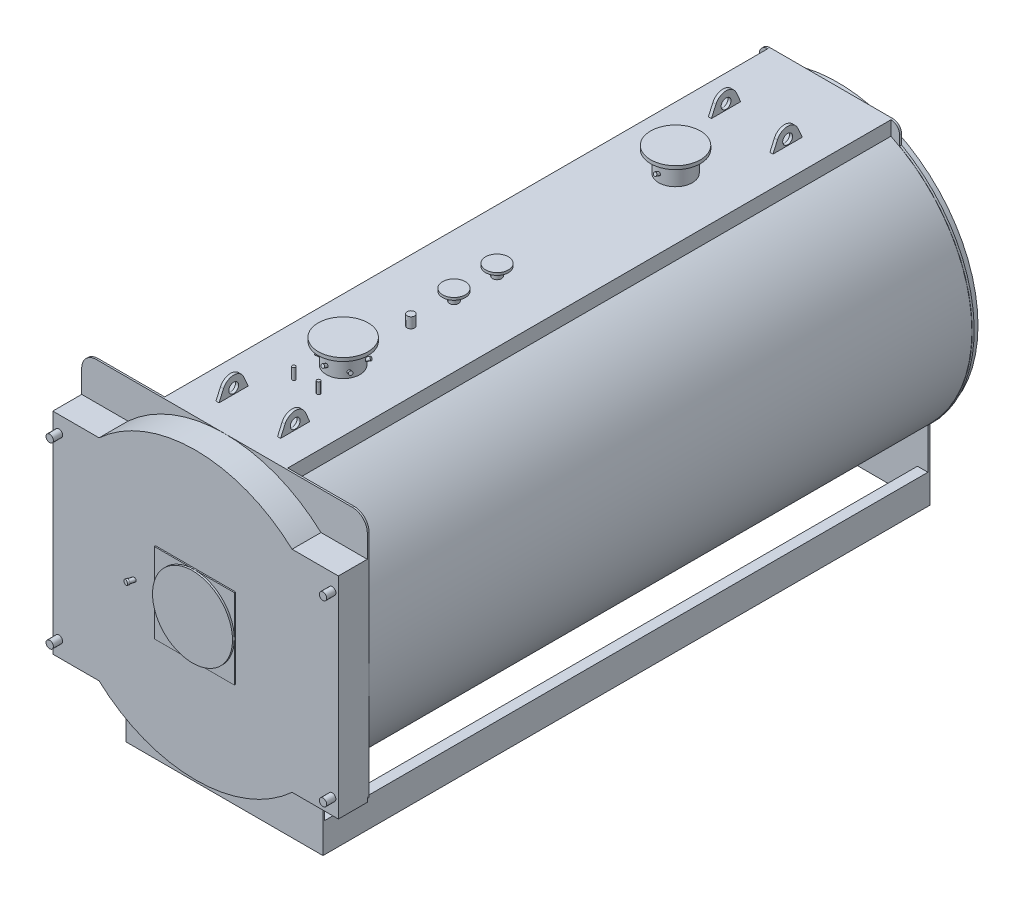
from build123d import *

# Parameters (mm, degrees)
PIASTRA_ANTERIORE_DEPTH       = 14
CORPO_DEPTH                   = 4900
PIASTRA_POSTERIORE_DEPTH      = 16
BASAMENTO_DEPTH               = 4900
ESTRUSIONE_ESTRUSIONE3_DEPTH  = 235
SCHIZZO8_W                    = 650
SCHIZZO8_H                    = 650
ESTRUSIONE_ESTRUSIONE4_DEPTH  = 10
SCHIZZO9_R                    = 325
ESTRUSIONE_ESTRUSIONE5_DEPTH  = 15
SCHIZZO12_R                   = 30
ESTRUSIONE_ESTRUSIONE6_DEPTH  = 75
SCHIZZO13_R                   = 136.5
ESTRUSIONE_ESTRUSIONE7_DEPTH  = 1355
SCHIZZO14_R                   = 202.5
ESTRUSIONE_ESTRUSIONE8_DEPTH  = 28
SCHIZZO13_3_R                 = 36.5
ESTRUSIONE_ESTRUSIONE9_DEPTH  = 1250
SCHIZZO15_R                   = 92.5
ESTRUSIONE_ESTRUSIONE10_DEPTH = 20
SCHIZZO13_4_R                 = 30.15
ESTRUSIONE_ESTRUSIONE11_DEPTH = 1245
SCHIZZO13_5_R                 = 13.35
ESTRUSIONE_ESTRUSIONE12_DEPTH = 1250
RIPETIZIONECIRCOLARE1_COUNT   = 3
SCHIZZO21_R                   = 24.15
ESTRUSIONE_ESTRUSIONE13_DEPTH = 149
SCHIZZO21_3_R                 = 24.15
ESTRUSIONE_ESTRUSIONE14_DEPTH = 50
SCHIZZO22_R                   = 75
ESTRUSIONE_ESTRUSIONE15_DEPTH = 16
GOLFARE_START                 = 250
SCHIZZO23_R                   = 40
GOLFARE_DEPTH                 = 12.5


with BuildPart() as part:
    # Schizzo1 → piastra anteriore (new body)
    with BuildSketch(Plane.XY):
        with BuildLine():
            Line((-1040, 2570), (1040, 2570))
            ThreePointArc((1040, 2570), (1124.852813742, 2534.852813742), (1160, 2450))
            Line((1160, 2450), (1160, 595))
            ThreePointArc((1160, 595), (1148.284271247, 566.715728753), (1120, 555))
            Line((1120, 555), (800, 555))
            Line((800, 555), (800, 0))
            Line((800, 0), (-800, 0))
            Line((-800, 0), (-800, 555))
            Line((-800, 555), (-1120, 555))
            ThreePointArc((-1120, 555), (-1148.284271247, 566.715728753), (-1160, 595))
            Line((-1160, 595), (-1160, 2450))
            ThreePointArc((-1160, 2450), (-1124.852813742, 2534.852813742), (-1040, 2570))
        make_face()
    extrude(amount=-PIASTRA_ANTERIORE_DEPTH)

    # Schizzo2 → corpo (add)
    with BuildSketch(Plane(origin=(0, 0, -14), x_dir=(-1, 0, 0), z_dir=(0, 0, -1))):
        with BuildLine():
            Line((500, 2453.937857346), (500, 2570))
            Line((500, 2570), (-500, 2570))
            Line((-500, 2570), (-500, 2453.937857346))
            ThreePointArc((-500, 2453.937857346), (0, 252.5), (500, 2453.937857346))
        make_face()
        with BuildLine():
            Line((490, 2447.620474933), (490, 2560))
            Line((490, 2560), (-490, 2560))
            Line((-490, 2560), (-490, 2447.620474933))
            ThreePointArc((-490, 2447.620474933), (0, 262.5), (490, 2447.620474933))
        make_face(mode=Mode.SUBTRACT)
    extrude(amount=CORPO_DEPTH)

    # Schizzo3 → piastra posteriore (add)
    with BuildSketch(Plane(origin=(0, 0, -4914), x_dir=(-1, 0, 0), z_dir=(0, 0, -1))):
        with BuildLine():
            Line((-570, 2420.296986039), (-570, 2500))
            ThreePointArc((-570, 2500), (-549.497474683, 2549.497474683), (-500, 2570))
            Line((-500, 2570), (500, 2570))
            ThreePointArc((500, 2570), (549.497474683, 2549.497474683), (570, 2500))
            Line((570, 2500), (570, 2420.296986039))
            ThreePointArc((570, 2420.296986039), (1151.140623094, 1553.091809212), (800, 570))
            Line((800, 570), (800, 0))
            Line((800, 0), (-800, 0))
            Line((-800, 0), (-800, 570))
            ThreePointArc((-800, 570), (-1151.140623094, 1553.091809212), (-570, 2420.296986039))
        make_face()
    extrude(amount=PIASTRA_POSTERIORE_DEPTH)

    # Schizzo5 → camera fumo (revolve)
    with BuildSketch(Plane(origin=(0, 0, 0), x_dir=(0, 0, -1), z_dir=(1, 0, 0)), mode=Mode.PRIVATE) as camera_fumo_sk:
        Polygon((4981, 1759), (5084, 1759), (5084, 1800), (5089, 1800), (5089, 1754), (4981, 1754), (4981, 1410), (4930, 1410), (4930, 2550), (4981, 2550), align=None)
    revolve(camera_fumo_sk.sketch.rotate(Axis((0, 1410, -4914), (0, 0, -1)), 90), axis=Axis((0, 1410, -4914), (0, 0, -1)))  # turned: the seam where the file's is

    # Schizzo6 → basamento (add)
    with BuildSketch(Plane(origin=(0, 0, -14), x_dir=(-1, 0, 0), z_dir=(0, 0, -1))):
        Polygon((-715, 0), (-800, 0), (-800, 240), (-715, 240), (-715, 230), (-790, 230), (-790, 10), (-715, 10), align=None)
    basamento = extrude(amount=BASAMENTO_DEPTH)

    # Specchia2: basamento across plane
    add(basamento.mirror(Plane(origin=(0, 0, 0), x_dir=(0, 0, 1), z_dir=(1, 0, 0))))

    # Schizzo7 → Estrusione-Estrusione3 (add)
    with BuildSketch(Plane.XY):
        with BuildLine():
            Line((783.948340135, 2265), (1160, 2265))
            Line((1160, 2265), (1160, 555))
            Line((1160, 555), (783.948340135, 555))
            ThreePointArc((783.948340135, 555), (0, 250), (-783.948340135, 555))
            Line((-783.948340135, 555), (-1160, 555))
            Line((-1160, 555), (-1160, 2265))
            Line((-1160, 2265), (-783.948340135, 2265))
            ThreePointArc((-783.948340135, 2265), (0, 2570), (783.948340135, 2265))
        make_face()
    extrude(amount=ESTRUSIONE_ESTRUSIONE3_DEPTH)

    # Schizzo8 → Estrusione-Estrusione4 (add)
    with BuildSketch(Plane.XY.offset(235)):
        with Locations((0, 1410)):
            Rectangle(SCHIZZO8_W, SCHIZZO8_H)
    extrude(amount=ESTRUSIONE_ESTRUSIONE4_DEPTH)

    # Schizzo9 → Estrusione-Estrusione5 (add)
    with BuildSketch(Plane.XY.offset(245)):
        with Locations((0, 1410)):
            Circle(SCHIZZO9_R)
    extrude(amount=ESTRUSIONE_ESTRUSIONE5_DEPTH)

    # Schizzo11 → Rivoluzione2 (revolve)
    with BuildSketch(Plane(origin=(0, 1410, 0), x_dir=(1, 0, 0), z_dir=(0, 1, 0)), mode=Mode.PRIVATE) as rivoluzione2_sk:
        Polygon((-514.268693957, -288.251490803), (-496.162357162, -220.677721947), (-480.031395863, -225), (-493.996627936, -277.118955636), (-490.809072709, -277.973058485), (-494.950177431, -293.427871705), align=None)
    revolve(rivoluzione2_sk.sketch.rotate(Axis((-500, 1410, 235), (-0.258819045, 0, 0.965925826)), 180), axis=Axis((-500, 1410, 235), (-0.258819045, 0, 0.965925826)))  # turned: the seam where the file's is

    # Schizzo12 → Estrusione-Estrusione6 (add)
    with BuildSketch(Plane.XY.offset(235)):
        with Locations((-1110, 2135)):
            Circle(SCHIZZO12_R)
        with Locations(Location((1110, 2135, 0), (0, 0, 180))):  # turned: the seam where the file's is
            Circle(SCHIZZO12_R)
        with Locations((1110, 685)):
            Circle(SCHIZZO12_R)
        with Locations(Location((-1110, 685, 0), (0, 0, 180))):  # turned: the seam where the file's is
            Circle(SCHIZZO12_R)
    extrude(amount=ESTRUSIONE_ESTRUSIONE6_DEPTH)

    # Schizzo13 → Estrusione-Estrusione7 (add)
    with BuildSketch(Plane(origin=(0, 1410, 0), x_dir=(1, 0, 0), z_dir=(0, 1, 0))):
        with Locations(Location((0, 964, 0), (0, 0, 270))):  # turned: the seam where the file's is
            Circle(SCHIZZO13_R)
        with Locations(Location((0, 3664, 0), (0, 0, 270))):  # turned: the seam where the file's is
            Circle(SCHIZZO13_R)
    extrude(amount=ESTRUSIONE_ESTRUSIONE7_DEPTH)

    # Schizzo14 → Estrusione-Estrusione8 (add)
    with BuildSketch(Plane(origin=(0, 2765, 0), x_dir=(1, 0, 0), z_dir=(0, 1, 0))):
        with Locations(Location((0, 964, 0), (0, 0, 270))):  # turned: the seam where the file's is
            Circle(SCHIZZO14_R)
        with Locations(Location((0, 3664, 0), (0, 0, 270))):  # turned: the seam where the file's is
            Circle(SCHIZZO14_R)
    extrude(amount=-ESTRUSIONE_ESTRUSIONE8_DEPTH)

    # Schizzo13_3 → Estrusione-Estrusione9 (add)
    with BuildSketch(Plane(origin=(0, 1410, 0), x_dir=(1, 0, 0), z_dir=(0, 1, 0))):
        with Locations(Location((0, 2214, 0), (0, 0, 270))):  # turned: the seam where the file's is
            Circle(SCHIZZO13_3_R)
        with Locations(Location((0, 1864, 0), (0, 0, 270))):  # turned: the seam where the file's is
            Circle(SCHIZZO13_3_R)
    extrude(amount=ESTRUSIONE_ESTRUSIONE9_DEPTH)

    # Schizzo15 → Estrusione-Estrusione10 (add)
    with BuildSketch(Plane(origin=(0, 2660, 0), x_dir=(1, 0, 0), z_dir=(0, 1, 0))):
        with Locations(Location((0, 2214, 0), (0, 0, 270))):  # turned: the seam where the file's is
            Circle(SCHIZZO15_R)
        with Locations(Location((0, 1864, 0), (0, 0, 270))):  # turned: the seam where the file's is
            Circle(SCHIZZO15_R)
    extrude(amount=-ESTRUSIONE_ESTRUSIONE10_DEPTH)

    # Schizzo13_4 → Estrusione-Estrusione11 (add)
    with BuildSketch(Plane(origin=(0, 1410, 0), x_dir=(1, 0, 0), z_dir=(0, 1, 0))):
        with Locations(Location((0, 1514, 0), (0, 0, 270))):  # turned: the seam where the file's is
            Circle(SCHIZZO13_4_R)
    extrude(amount=ESTRUSIONE_ESTRUSIONE11_DEPTH)

    # Schizzo13_5 → Estrusione-Estrusione12 (add)
    with BuildSketch(Plane(origin=(0, 1410, 0), x_dir=(1, 0, 0), z_dir=(0, 1, 0))):
        with Locations(Location((-100, 664, 0), (0, 0, 270))):  # turned: the seam where the file's is
            Circle(SCHIZZO13_5_R)
        with Locations(Location((100, 664, 0), (0, 0, 270))):  # turned: the seam where the file's is
            Circle(SCHIZZO13_5_R)
    extrude(amount=ESTRUSIONE_ESTRUSIONE12_DEPTH)

    # Schizzo16 → Rivoluzione3 (revolve)
    with BuildSketch(Plane(origin=(0, 0, 0), x_dir=(0, 0, -1), z_dir=(1, 0, 0))):
        Polygon((3498.199829072, 2645.664390077), (3502.8, 2658.303255826), (3549.784631039, 2641.20224866), (3545.184460112, 2628.56338291), align=None)
    revolve(axis=Axis((0, 2635, -3527.5), (0, 0.342020143, 0.939692621)))

    # Schizzo17 → Rivoluzione4 (revolve)
    with BuildSketch(Plane(origin=(0, 0, 0), x_dir=(0, 0, -1), z_dir=(1, 0, 0))):
        Polygon((798.199829072, 2645.664390077), (802.8, 2658.303255826), (849.784631039, 2641.20224866), (845.184460112, 2628.56338291), align=None)
    rivoluzione4 = revolve(axis=Axis((0, 2635, -827.5), (0, 0.342020143, 0.939692621)))

    # Schizzo18 → Rivoluzione5 (revolve)
    with BuildSketch(Plane(origin=(0, 0, 0), x_dir=(0, 0, -1), z_dir=(1, 0, 0))):
        Polygon((1129.800170928, 2625.664390077), (1125.2, 2638.303255826), (1078.215368961, 2621.20224866), (1082.815539888, 2608.56338291), align=None)
    rivoluzione5 = revolve(axis=Axis((0, 2615, -1100.5), (0, -0.342020143, 0.939692621)))

    # RipetizioneCircolare1: Rivoluzione4, Rivoluzione5 ×3 about axis
    ripetizionecircolare1_axis = Axis((0, 0, -964), (0, 1, 0))
    add([rivoluzione4.rotate(ripetizionecircolare1_axis, i * 360 / RIPETIZIONECIRCOLARE1_COUNT) for i in range(1, RIPETIZIONECIRCOLARE1_COUNT)])
    add([rivoluzione5.rotate(ripetizionecircolare1_axis, i * 360 / RIPETIZIONECIRCOLARE1_COUNT) for i in range(1, RIPETIZIONECIRCOLARE1_COUNT)])

    # Schizzo21 → Estrusione-Estrusione13 (add)
    with BuildSketch(Plane(origin=(0, 0, -4930), x_dir=(-1, 0, 0), z_dir=(0, 0, -1))):
        with Locations((0, 125)):
            Circle(SCHIZZO21_R)
    extrude(amount=ESTRUSIONE_ESTRUSIONE13_DEPTH)

    # Schizzo21_3 → Estrusione-Estrusione14 (add)
    with BuildSketch(Plane(origin=(0, 0, -4930), x_dir=(-1, 0, 0), z_dir=(0, 0, -1))):
        with Locations((0, 260)):
            Circle(SCHIZZO21_3_R)
    extrude(amount=ESTRUSIONE_ESTRUSIONE14_DEPTH)

    # Schizzo22 → Estrusione-Estrusione15 (add)
    with BuildSketch(Plane(origin=(0, 0, -5079), x_dir=(-1, 0, 0), z_dir=(0, 0, -1))):
        with Locations((0, 125)):
            Circle(SCHIZZO22_R)
    extrude(amount=-ESTRUSIONE_ESTRUSIONE15_DEPTH)

    # Schizzo23 → golfare (add, symmetric)
    with BuildSketch(Plane(origin=(0, 0, 0), x_dir=(0, 0, -1), z_dir=(1, 0, 0)).offset(GOLFARE_START)):
        with BuildLine():
            Line((187, 2476), (187, 2556))
            Line((187, 2556), (229.707899924, 2652.441875159))
            ThreePointArc((229.707899924, 2652.441875159), (312, 2706), (394.292100076, 2652.441875159))
            Line((394.292100076, 2652.441875159), (437, 2556))
            Line((437, 2556), (437, 2476))
            Line((437, 2476), (187, 2476))
        make_face()
        with Locations((312, 2616)):
            Circle(SCHIZZO23_R, mode=Mode.SUBTRACT)
        with BuildLine():
            Line((4187, 2476), (4187, 2556))
            Line((4187, 2556), (4229.707899924, 2652.441875159))
            ThreePointArc((4229.707899924, 2652.441875159), (4312, 2706), (4394.292100076, 2652.441875159))
            Line((4394.292100076, 2652.441875159), (4437, 2556))
            Line((4437, 2556), (4437, 2476))
            Line((4437, 2476), (4187, 2476))
        make_face()
        with Locations((4312, 2616)):
            Circle(SCHIZZO23_R, mode=Mode.SUBTRACT)
    golfare = extrude(amount=GOLFARE_DEPTH, both=True)

    # Specchia3: golfare across plane
    add(golfare.mirror(Plane(origin=(0, 0, 0), x_dir=(0, 0, 1), z_dir=(1, 0, 0))))


solid = part.part
